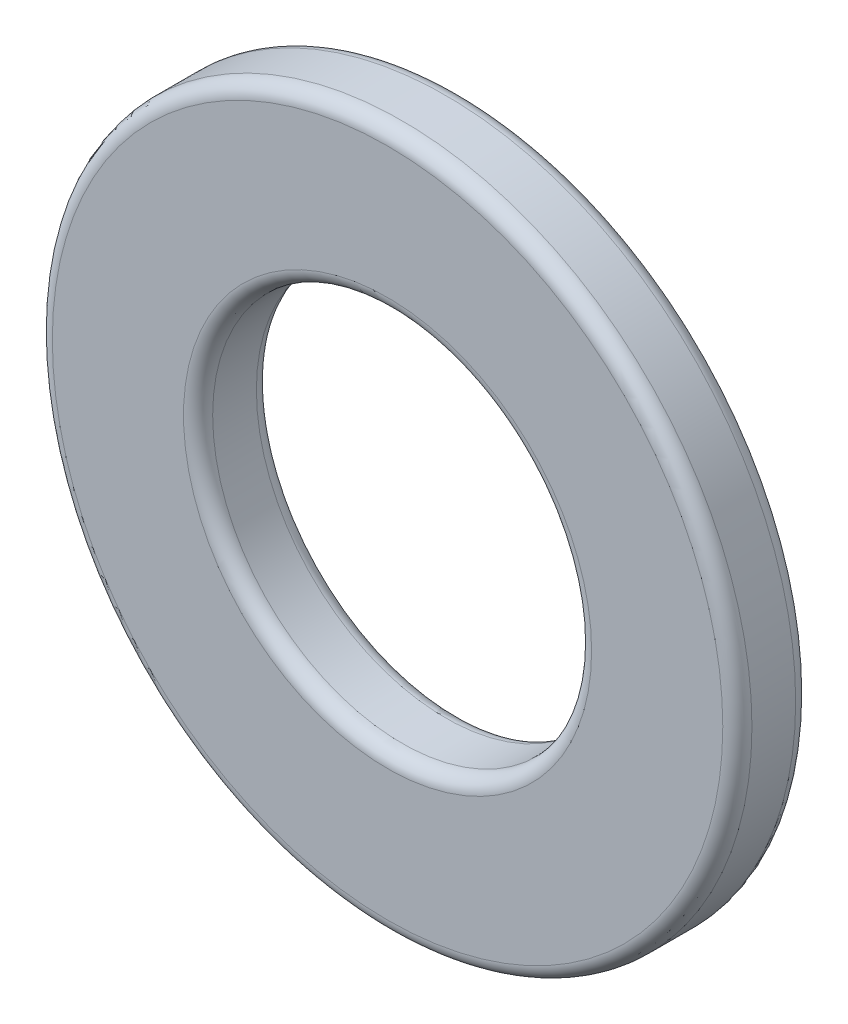
from build123d import *

# Parameters (mm, degrees)
SKETCH1_R           = 12
SKETCH1_R_2         = 6.5
BOSS_EXTRUDE1_DEPTH = 2.5
FILLET1_R           = 0.5


with BuildPart() as part:
    # Sketch1 → Boss-Extrude1 (new body)
    with BuildSketch(Plane.XY):
        Circle(SKETCH1_R)
        Circle(SKETCH1_R_2, mode=Mode.SUBTRACT)
    extrude(amount=BOSS_EXTRUDE1_DEPTH)

    # Fillet1
    fillet1_edges = [part.edges().sort_by_distance(p)[0] for p in [
        (-12, 0, 0),
        (-12, 0, 2.5),
        (-6.5, 0, 0),
        (-6.5, 0, 2.5),
    ]]
    fillet(fillet1_edges, radius=FILLET1_R)


solid = part.part
